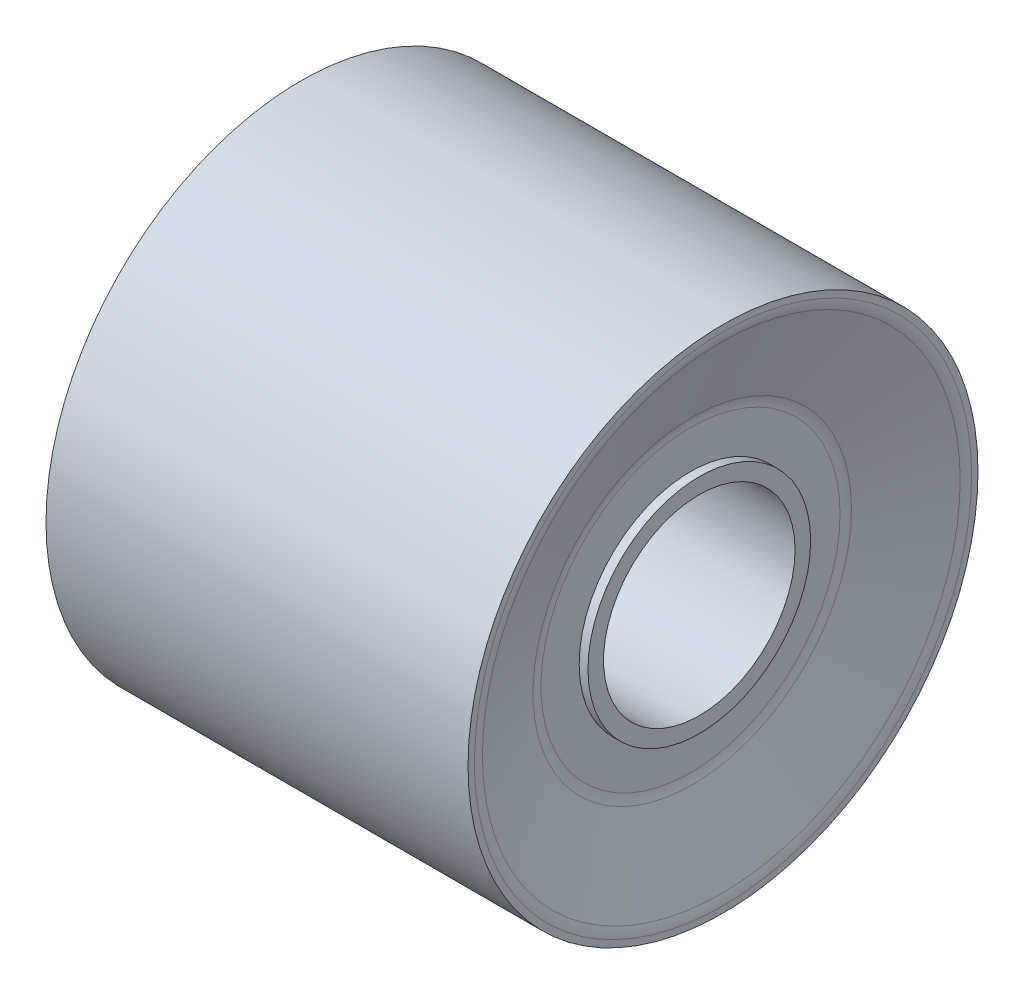
from build123d import *

# Parameters (mm, degrees)
FILLET2_R = 2


with BuildPart() as part:
    # Sketch1 → Revolve1 (revolve)
    with BuildSketch(Plane.XY):
        Polygon((-14.412217993, 18.021334137), (-14.412217993, 17.213777129), (-11.987191568, 10.920560913), (-11.987191568, 7.870061872), (-12.453293915, 7.870061872), (-12.453293915, 6.766705429), (-11.987191568, 6.766705429), (13.120112204, 6.766705429), (13.74017448, 6.766705429), (13.74017448, 7.870061872), (13.120112204, 7.870061872), (13.120112204, 10.920560913), (15.416727783, 17.213777129), (15.416727783, 18.021334137), align=None)
    revolve(axis=Axis((76.351551313, 0, 0), (-1, 0, 0)))

    # Fillet2
    fillet2_edges = [part.edges().sort_by_distance(p)[0] for p in [
        (15.416727783, -17.213777129, 0),
        (13.120112204, -10.920560913, 0),
        (-11.987191568, -10.920560913, 0),
        (-14.412217993, -17.213777129, 0),
    ]]
    fillet(fillet2_edges, radius=FILLET2_R)


solid = part.part
